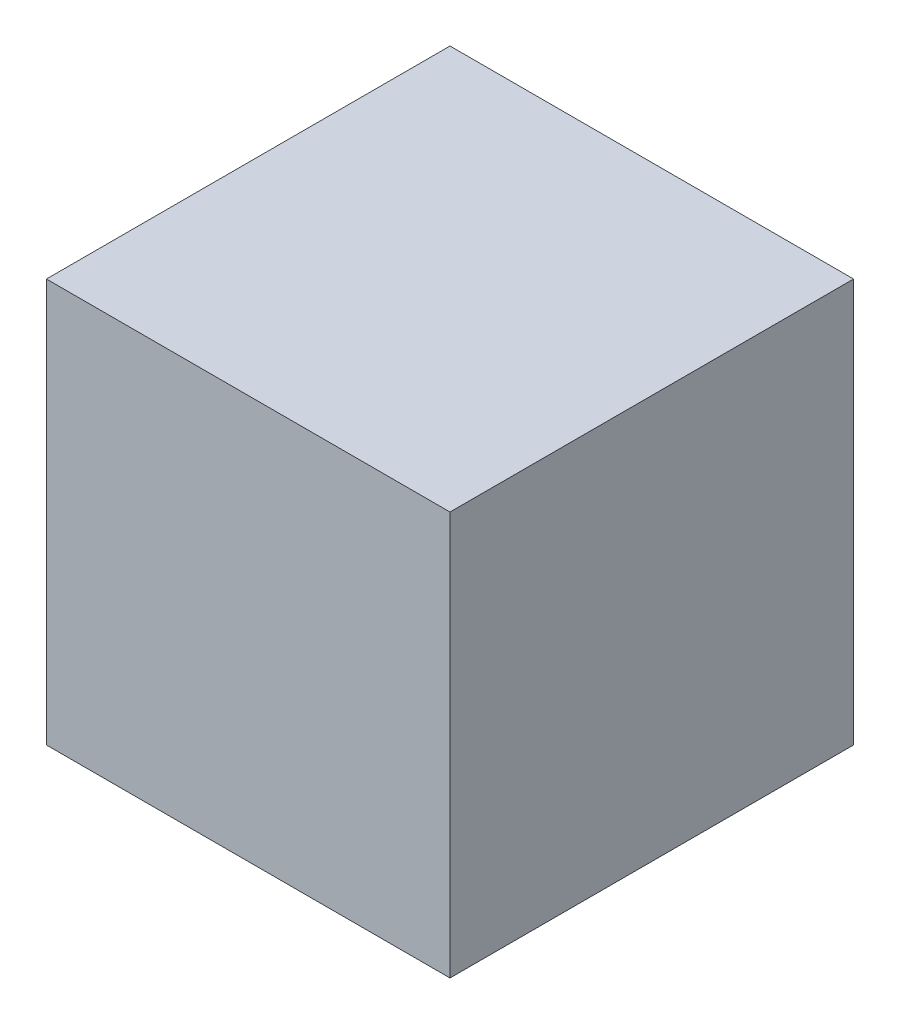
from build123d import *

# Parameters (mm, degrees)
SKETCH1_W      = 1.5875
SKETCH1_H      = 1.5875
EXTRUDE1_DEPTH = 0.79375


with BuildPart() as part:
    # Sketch1 → Extrude1 (new, symmetric)
    with BuildSketch(Plane(origin=(0, 0, 0), x_dir=(0, 0, -1), z_dir=(1, 0, 0))):
        Rectangle(SKETCH1_W, SKETCH1_H)
    extrude(amount=EXTRUDE1_DEPTH, both=True)


solid = part.part
